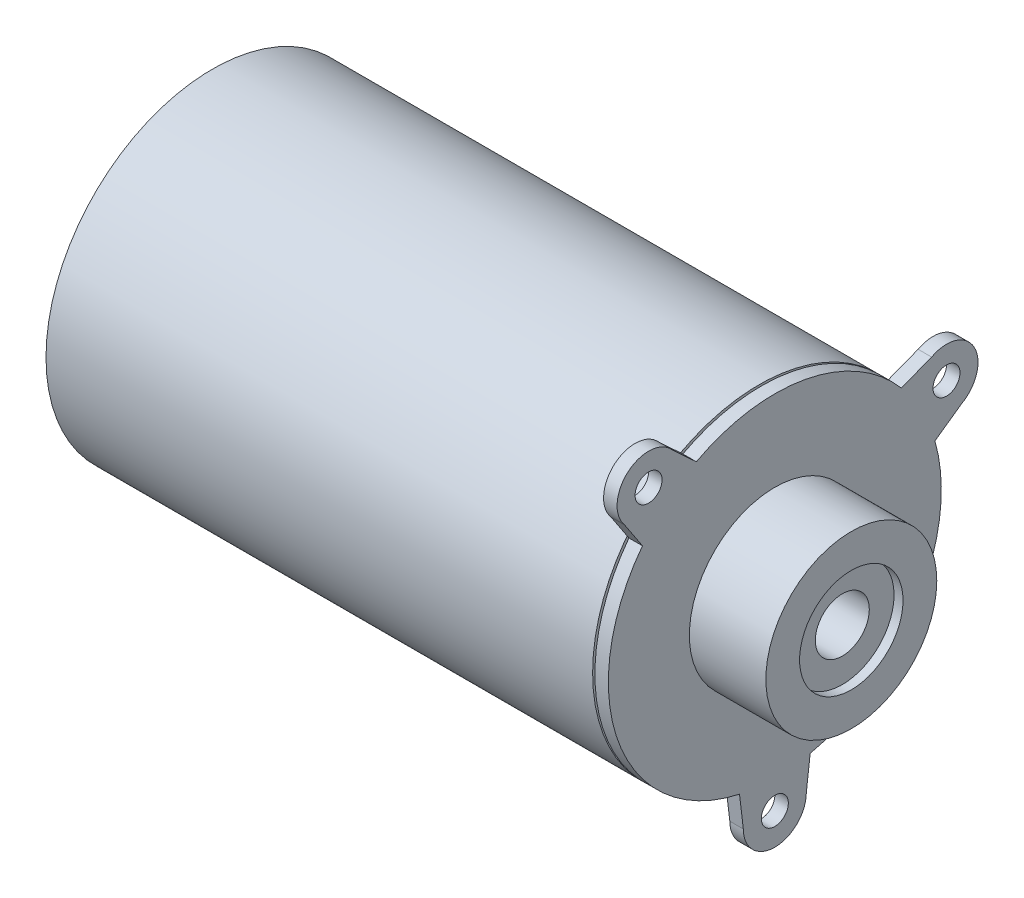
from build123d import *

# Parameters (mm, degrees)
SKETCH1_R               = 1.5
SKETCH1_R_2             = 18.5
SKETCH1_R_3             = 17.5
BOSS_EXTRUDE1_DEPTH     = 1.5
SKETCH1_4_R             = 18.5
SKETCH1_4_R_2           = 17.5
BOSS_EXTRUDE2_DEPTH     = 61.5
CUT_EXTRUDE1_START      = -61.5
SKETCH1_5_R             = 17.5
CUT_EXTRUDE1_DEPTH      = 6
SKETCH2_R               = 9.5
SKETCH2_R_2             = 5.75
BOSS_EXTRUDE3_DEPTH     = 8.5
SKETCH3_R               = 5.75
CUT_EXTRUDE2_DEPTH      = 1
SKETCH4_R               = 3
CUT_EXTRUDE3_DEPTH      = 79.183366667
CUT_EXTRUDE3_DEPTH_BACK = 79.183366667
CUT_EXTRUDE4_START      = -1.5
SKETCH5_R               = 18.5
SKETCH5_R_2             = 17.5
CUT_EXTRUDE4_DEPTH      = 0.25
SKETCH6_R               = 18.5
CUT_EXTRUDE5_DEPTH      = 0.5


with BuildPart() as part:
    # Sketch1 → Boss-Extrude1 (new body)
    with BuildSketch(Plane(origin=(0, 0, 0), x_dir=(0, 0, -1), z_dir=(1, 0, 0))):
        with BuildLine():
            ThreePointArc((-11.366411782, 18.755724012), (-16.300215512, 19.152688435), (-16.697179934, 14.218884704))
            Line((-16.697179934, 14.218884704), (-14.710366227, 11.218517079))
            ThreePointArc((-14.710366227, 11.218517079), (-11.99021817, 14.088458689), (-8.722294226, 16.31476581))
            Line((-8.722294226, 16.31476581), (-11.366411782, 18.755724012))
        make_face()
        with Locations((-14.031795858, 16.487304358)):
            Circle(SKETCH1_R, mode=Mode.SUBTRACT)
        Circle(SKETCH1_R_2)
        Circle(SKETCH1_R_3, mode=Mode.SUBTRACT)
        Circle(SKETCH1_R_3)
        with BuildLine():
            Line((17.42629206, 13.315286142), (14.061297684, 12.022059201))
            ThreePointArc((14.061297684, 12.022059201), (16.304113863, 8.74218915), (17.794831776, 5.059047546))
            Line((17.794831776, 5.059047546), (20.734147414, 7.146161977))
            ThreePointArc((20.734147414, 7.146161977), (22.164781819, 11.884651736), (17.42629206, 13.315286142))
        make_face()
        with Locations((19.080219737, 10.230724059)):
            Circle(SKETCH1_R, mode=Mode.SUBTRACT)
        with BuildLine():
            ThreePointArc((3.927811116, -18.078227232), (0, -18.5), (-3.927811116, -18.078227232))
            Line((-3.927811116, -18.078227232), (-3.5, -21.65))
            ThreePointArc((-3.5, -21.65), (0, -25.15), (3.5, -21.65))
            Line((3.5, -21.65), (3.927811116, -18.078227232))
        make_face()
        with Locations((0, -21.65)):
            Circle(SKETCH1_R, mode=Mode.SUBTRACT)
    extrude(amount=BOSS_EXTRUDE1_DEPTH)

    # Sketch1_4 → Boss-Extrude2 (add)
    with BuildSketch(Plane(origin=(0, 0, 0), x_dir=(0, 0, -1), z_dir=(1, 0, 0))):
        with Locations(Location((0, 0, 0), (0, 0, 142.669891736))):
            Circle(SKETCH1_4_R)
        Circle(SKETCH1_4_R_2, mode=Mode.SUBTRACT)
        Circle(SKETCH1_4_R_2)
    extrude(amount=-BOSS_EXTRUDE2_DEPTH)

    # Sketch1_5 → Cut-Extrude1 (cut)
    with BuildSketch(Plane(origin=(0, 0, 0), x_dir=(0, 0, -1), z_dir=(1, 0, 0)).offset(CUT_EXTRUDE1_START)):
        Circle(SKETCH1_5_R)
    extrude(amount=CUT_EXTRUDE1_DEPTH, mode=Mode.SUBTRACT)

    # Sketch2 → Boss-Extrude3 (add)
    with BuildSketch(Plane(origin=(1.5, 0, 0), x_dir=(0, 0, -1), z_dir=(1, 0, 0))):
        Circle(SKETCH2_R)
        Circle(SKETCH2_R_2, mode=Mode.SUBTRACT)
        Circle(SKETCH2_R_2)
    extrude(amount=BOSS_EXTRUDE3_DEPTH)

    # Sketch3 → Cut-Extrude2 (cut)
    with BuildSketch(Plane(origin=(10, 0, 0), x_dir=(0, 0, -1), z_dir=(1, 0, 0))):
        Circle(SKETCH3_R)
    extrude(amount=-CUT_EXTRUDE2_DEPTH, mode=Mode.SUBTRACT)

    # Sketch4 → Cut-Extrude3 (cut, two sides)
    with BuildSketch(Plane(origin=(9, 0, 0), x_dir=(0, 0, -1), z_dir=(1, 0, 0))) as cut_extrude3_sk:
        Circle(SKETCH4_R)
    extrude(amount=CUT_EXTRUDE3_DEPTH, mode=Mode.SUBTRACT)
    extrude(cut_extrude3_sk.sketch, amount=-CUT_EXTRUDE3_DEPTH_BACK, mode=Mode.SUBTRACT)

    # Sketch5 → Cut-Extrude4 (cut)
    with BuildSketch(Plane(origin=(1.5, 0, 0), x_dir=(0, 0, -1), z_dir=(1, 0, 0)).offset(CUT_EXTRUDE4_START)):
        Circle(SKETCH5_R)
        Circle(SKETCH5_R_2, mode=Mode.SUBTRACT)
    extrude(amount=-CUT_EXTRUDE4_DEPTH, mode=Mode.SUBTRACT)

    # Sketch6 → Cut-Extrude5 (cut)
    with BuildSketch(Plane.ZY.offset(61.5)):
        Circle(SKETCH6_R)
    extrude(amount=-CUT_EXTRUDE5_DEPTH, mode=Mode.SUBTRACT)


solid = part.part
